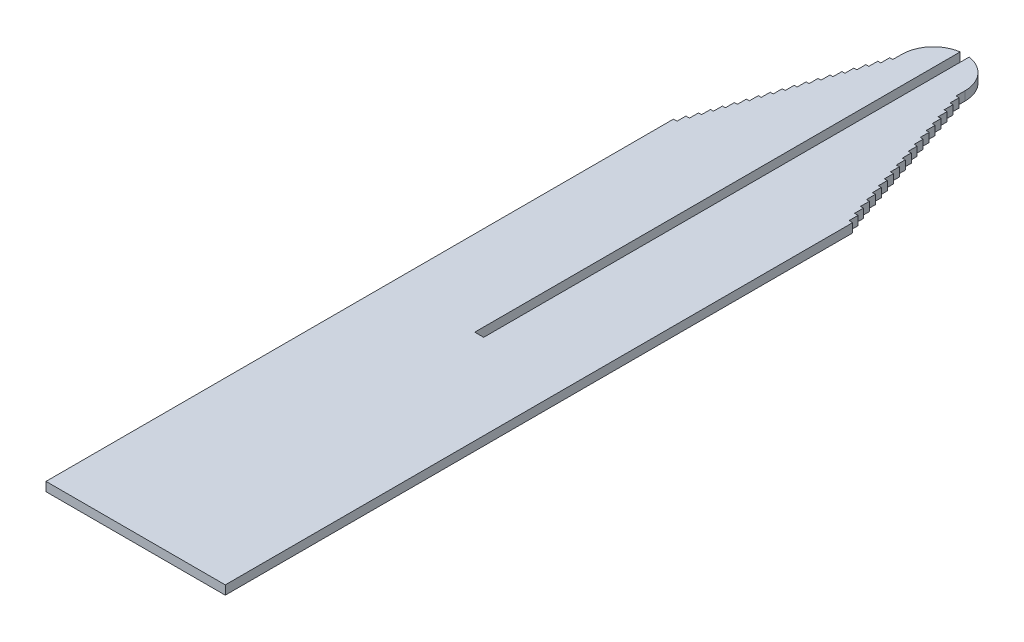
from build123d import *

# Parameters (mm, degrees)
SALIENTE_EXTRUIR1_DEPTH = 3


with BuildPart() as part:
    # Croquis1 → Saliente-Extruir1 (new body)
    with BuildSketch(Plane(origin=(0, 0, 0), x_dir=(1, 0, 0), z_dir=(0, 1, 0))):
        with BuildLine():
            Line((0, 0), (60, 0))
            Line((60, 0), (60, 210))
            Line((60, 210), (58.8, 210))
            Line((58.8, 210), (58.8, 213))
            Line((58.8, 213), (57.6, 213))
            Line((57.6, 213), (57.6, 216))
            Line((57.6, 216), (56.6, 216))
            Line((56.6, 216), (56.6, 219))
            Line((56.6, 219), (55.6, 219))
            Line((55.6, 219), (55.6, 222))
            Line((55.6, 222), (54.6, 222))
            Line((54.6, 222), (54.6, 225))
            Line((54.6, 225), (53.6, 225))
            Line((53.6, 225), (53.6, 228))
            Line((53.6, 228), (52.6, 228))
            Line((52.6, 228), (52.6, 231))
            Line((52.6, 231), (51.6, 231))
            Line((51.6, 231), (51.6, 234))
            Line((51.6, 234), (50.6, 234))
            Line((50.6, 234), (50.6, 237))
            Line((50.6, 237), (49.6, 237))
            Line((49.6, 237), (49.6, 240))
            Line((49.6, 240), (48.6, 240))
            Line((48.6, 240), (48.6, 243))
            Line((48.6, 243), (47.6, 243))
            Line((47.6, 243), (47.6, 246))
            Line((47.6, 246), (46.6, 246))
            Line((46.6, 246), (46.6, 249))
            Line((46.6, 249), (45.6, 249))
            Line((45.6, 249), (45.6, 252))
            Line((45.6, 252), (44.6, 252))
            Line((44.6, 252), (44.6, 255))
            Line((44.6, 255), (43.6, 255))
            Line((43.6, 255), (43.6, 258))
            Line((43.6, 258), (42.6, 258))
            Line((42.6, 258), (42.6, 261))
            Line((42.6, 261), (41.6, 261))
            Line((41.6, 261), (41.6, 264))
            Line((41.6, 264), (40.575, 264))
            Line((40.575, 264), (40.575, 267))
            ThreePointArc((40.575, 267), (37.990404402, 273.927052945), (31.5, 277.468076471))
            Line((31.5, 277.468076471), (31.5, 115))
            Line((31.5, 115), (28.5, 115))
            Line((28.5, 115), (28.5, 277.468076471))
            ThreePointArc((28.5, 277.468076471), (22.009595598, 273.927052945), (19.425, 267))
            Line((19.425, 267), (19.425, 264))
            Line((19.425, 264), (18.4, 264))
            Line((18.4, 264), (18.4, 261))
            Line((18.4, 261), (17.4, 261))
            Line((17.4, 261), (17.4, 258))
            Line((17.4, 258), (16.4, 258))
            Line((16.4, 258), (16.4, 255))
            Line((16.4, 255), (15.4, 255))
            Line((15.4, 255), (15.4, 252))
            Line((15.4, 252), (14.4, 252))
            Line((14.4, 252), (14.4, 249))
            Line((14.4, 249), (13.4, 249))
            Line((13.4, 249), (13.4, 246))
            Line((13.4, 246), (12.4, 246))
            Line((12.4, 246), (12.4, 243))
            Line((12.4, 243), (11.4, 243))
            Line((11.4, 243), (11.4, 240))
            Line((11.4, 240), (10.4, 240))
            Line((10.4, 240), (10.4, 237))
            Line((10.4, 237), (9.4, 237))
            Line((9.4, 237), (9.4, 234))
            Line((9.4, 234), (8.4, 234))
            Line((8.4, 234), (8.4, 231))
            Line((8.4, 231), (7.4, 231))
            Line((7.4, 231), (7.4, 228))
            Line((7.4, 228), (6.4, 228))
            Line((6.4, 228), (6.4, 225))
            Line((6.4, 225), (5.4, 225))
            Line((5.4, 225), (5.4, 222))
            Line((5.4, 222), (4.4, 222))
            Line((4.4, 222), (4.4, 219))
            Line((4.4, 219), (3.4, 219))
            Line((3.4, 219), (3.4, 216))
            Line((3.4, 216), (2.4, 216))
            Line((2.4, 216), (2.4, 213))
            Line((2.4, 213), (1.2, 213))
            Line((1.2, 213), (1.2, 210))
            Line((1.2, 210), (0, 210))
            Line((0, 210), (0, 0))
        make_face()
    extrude(amount=SALIENTE_EXTRUIR1_DEPTH)


solid = part.part
